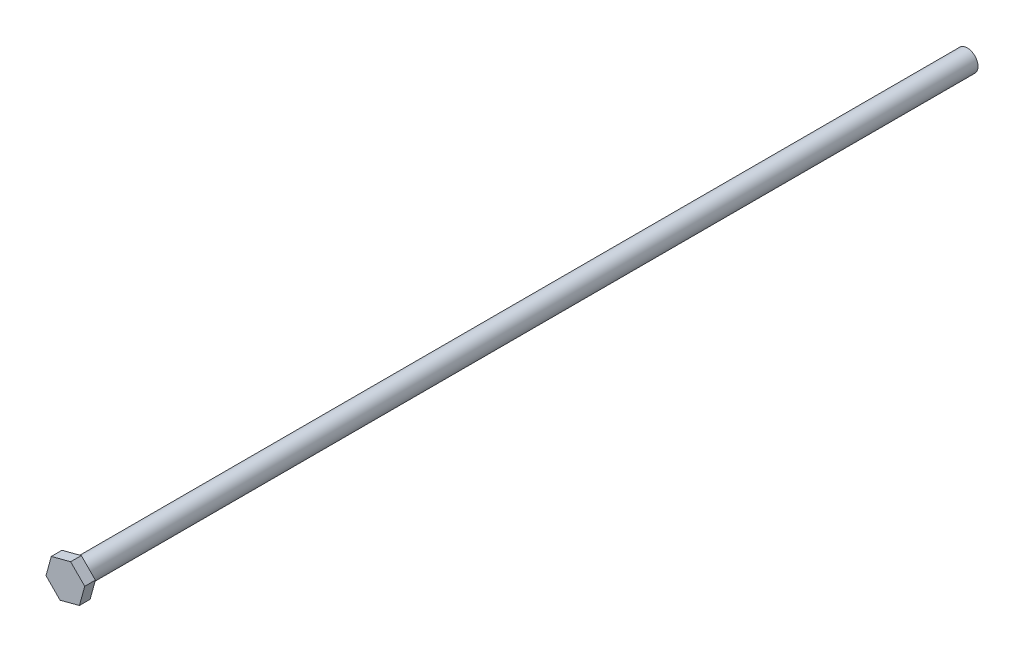
from build123d import *

# Parameters (mm, degrees)
SKETCH1_R           = 2
BOSS_EXTRUDE1_DEPTH = 167
BOSS_EXTRUDE2_DEPTH = 2


with BuildPart() as part:
    # Sketch1 → Boss-Extrude1 (new body)
    with BuildSketch(Plane.XY):
        Circle(SKETCH1_R)
    extrude(amount=BOSS_EXTRUDE1_DEPTH)

    # Sketch2 → Boss-Extrude2 (add)
    with BuildSketch(Plane.XY.offset(167)):
        Polygon((-2.635845892, 2.667361324), (0.992079722, 3.616390165), (3.627925614, 0.949028841), (2.635845892, -2.667361324), (-0.992079722, -3.616390165), (-3.627925614, -0.949028841), align=None)
    extrude(amount=BOSS_EXTRUDE2_DEPTH)


solid = part.part
